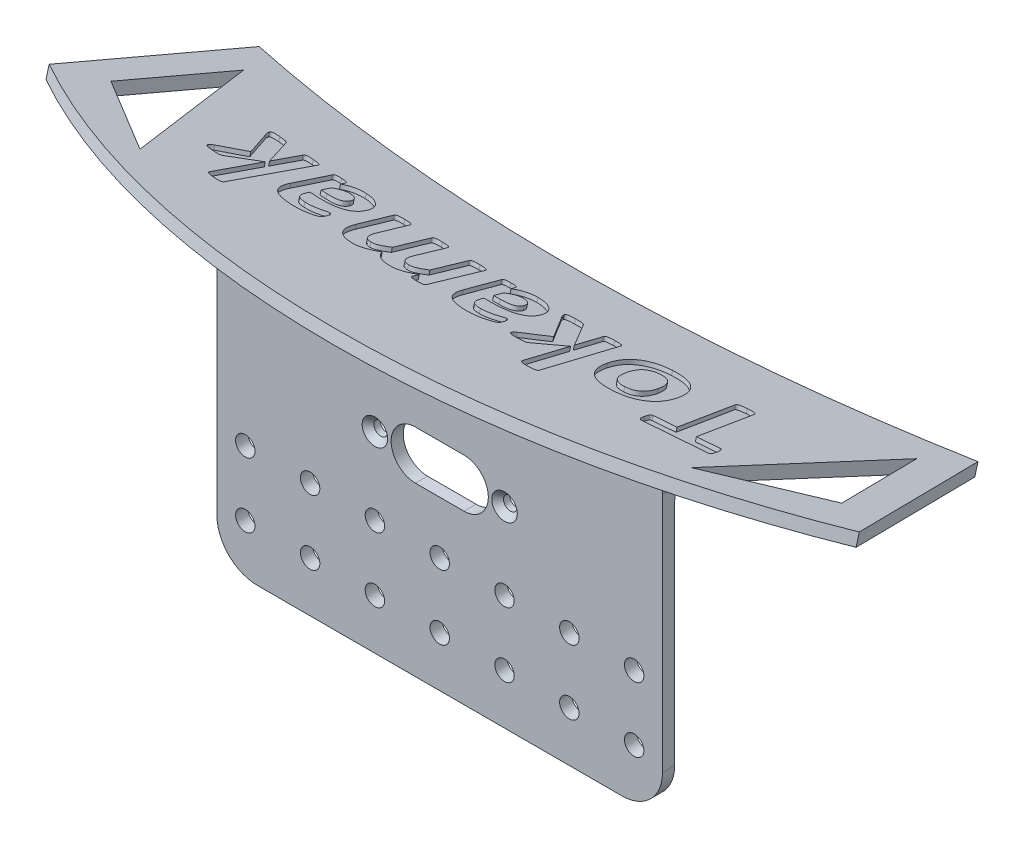
from build123d import *

# Parameters (mm, degrees)
SKETCH2_W                                           = 110
SKETCH2_H                                           = 80
BOSS_EXTRUDE1_DEPTH                                 = 3
BOSS_EXTRUDE2_DEPTH                                 = 3
FILLET1_R                                           = 10
FILLET2_R                                           = 10
SKETCH4_R                                           = 2.4
CUT_EXTRUDE1_DEPTH                                  = 45.144379945
CUT_EXTRUDE2_DEPTH                                  = 88.049621733
CUT_EXTRUDE3_DEPTH                                  = 45.144379945
CUT_EXTRUDE11_DEPTH                                 = 1
CSK_FOR_M3_COUNTERSUNK_FLAT_HEAD_SCREW1_D           = 3.4
CSK_FOR_M3_COUNTERSUNK_FLAT_HEAD_SCREW1_CSINK_D     = 6.3
CSK_FOR_M3_COUNTERSUNK_FLAT_HEAD_SCREW1_CSINK_ANGLE = 90


with BuildPart() as part:
    # Sketch2 → Boss-Extrude1 (new body)
    with BuildSketch(Plane.XY):
        Rectangle(SKETCH2_W, SKETCH2_H)
    extrude(amount=BOSS_EXTRUDE1_DEPTH)

    # Sketch3 → Boss-Extrude2 (add)
    with BuildSketch(Plane(origin=(0, 36.570508076, -9.799038106), x_dir=(-1, 0, 0), z_dir=(0, 0.965925826, -0.258819045))):
        with BuildLine():
            Line((-100, 10.352761804), (-88.746133918, -31.647238196))
            ThreePointArc((-88.746133918, -31.647238196), (0, -19.647238196), (88.746133918, -31.647238196))
            Line((88.746133918, -31.647238196), (100, 10.352761804))
            ThreePointArc((100, 10.352761804), (0, 40.352761804), (-100, 10.352761804))
        make_face()
    extrude(amount=BOSS_EXTRUDE2_DEPTH)

    # Fillet1
    fillet1_edges = [part.edges().sort_by_distance(p)[0] for p in [
        (0, 39.196152423, 0),
        (55, 39.598076211, 1.5),
        (-55, 39.598076211, 1.5),
        (0, 40, 3),
    ]]
    fillet(fillet1_edges, radius=FILLET1_R)

    # Fillet2
    fillet2_edges = [part.edges().sort_by_distance(p)[0] for p in [
        (55, -40, 1.5),
        (-55, -40, 1.5),
    ]]
    fillet(fillet2_edges, radius=FILLET2_R)

    # Sketch4 → Cut-Extrude1 (cut, through all)
    with BuildSketch(Plane.XY.offset(3)):
        with Locations((-48, -11.627322451)):
            Circle(SKETCH4_R)
        with Locations((-48, -27.627322451)):
            Circle(SKETCH4_R)
        with Locations((-32, -11.627322451)):
            Circle(SKETCH4_R)
        with Locations((-32, -27.627322451)):
            Circle(SKETCH4_R)
        with Locations((-16, -11.627322451)):
            Circle(SKETCH4_R)
        with Locations((-16, -27.627322451)):
            Circle(SKETCH4_R)
        with Locations((0, -11.627322451)):
            Circle(SKETCH4_R)
        with Locations((0, -27.627322451)):
            Circle(SKETCH4_R)
        with Locations((16, -11.627322451)):
            Circle(SKETCH4_R)
        with Locations((16, -27.627322451)):
            Circle(SKETCH4_R)
        with Locations((32, -11.627322451)):
            Circle(SKETCH4_R)
        with Locations((32, -27.627322451)):
            Circle(SKETCH4_R)
        with Locations((48, -11.627322451)):
            Circle(SKETCH4_R)
        with Locations((48, -27.627322451)):
            Circle(SKETCH4_R)
    extrude(amount=-CUT_EXTRUDE1_DEPTH, mode=Mode.SUBTRACT)

    # Sketch7 → Cut-Extrude2 (cut, through all)
    with BuildSketch(Plane(origin=(0, 39.468285555, -10.575495241), x_dir=(1, 0, 0), z_dir=(0, 0.965925826, -0.258819045))):
        Polygon((90.202041029, -4.695907555), (83.089279668, 21.849279225), (68.084935833, -20.182471336), align=None)
    cut_extrude2 = extrude(amount=-CUT_EXTRUDE2_DEPTH, mode=Mode.SUBTRACT)

    # Mirror1: Cut-Extrude2 across plane
    add(cut_extrude2.mirror(Plane(origin=(0, 0, 0), x_dir=(0, 0, 1), z_dir=(1, 0, 0))), mode=Mode.SUBTRACT)

    # Sketch8 → Cut-Extrude3 (cut, through all)
    with BuildSketch(Plane.XY.offset(3)):
        with BuildLine():
            Line((-6, 13.372677549), (6, 13.372677549))
            ThreePointArc((6, 13.372677549), (12, 7.372677549), (6, 1.372677549))
            Line((6, 1.372677549), (-6, 1.372677549))
            ThreePointArc((-6, 1.372677549), (-12, 7.372677549), (-6, 13.372677549))
        make_face()
    extrude(amount=-CUT_EXTRUDE3_DEPTH, mode=Mode.SUBTRACT)

    # Sketch9 → Cut-Extrude11 (cut)
    with BuildSketch(Plane(origin=(0, 39.468285555, -10.575495241), x_dir=(-1, 0, 0), z_dir=(0, 0.965925826, -0.258819045))):
        with BuildLine():
            add(Edge.make_bspline(
                [(-49.435540802, 12.912574756), (-49.419047282, 12.766806093), (-49.38868423, 12.498459394), (-49.373489441, 12.126485762), (-49.381697124, 11.817365886), (-49.431096559, 11.568766235), (-49.50041131, 11.372829069), (-49.599662798, 11.22991395), (-49.722304379, 11.133085391), (-49.816775888, 11.109903843), (-49.863543253, 11.098428003)],
                knots=[0, 0, 0, 0, 0.000439913, 0.000809839, 0.001116597, 0.001364597, 0.001567826, 0.001735181, 0.001881091, 0.002024135, 0.002024135, 0.002024135, 0.002024135], degree=3))
            Line((-49.863543253, 11.098428003), (-55.130891599, 10.480742648))
            Line((-55.130891599, 10.480742648), (-53.13678927, -6.483718136))
            add(Edge.make_bspline(
                [(-53.13678927, -6.483718136), (-53.13656824, -6.536066112), (-53.136115475, -6.643297684), (-53.203886208, -6.802456658), (-53.345090317, -6.938566716), (-53.550498038, -7.060477804), (-53.840402377, -7.1564185), (-54.209462235, -7.259588735), (-54.67606465, -7.350862804), (-55.02031991, -7.393958157), (-55.208710226, -7.417541666)],
                knots=[0, 0, 0, 0, 0.000155941, 0.000319435, 0.000501742, 0.000735299, 0.001030744, 0.001414234, 0.001885432, 0.002454959, 0.002454959, 0.002454959, 0.002454959], degree=3))
            add(Edge.make_bspline(
                [(-55.208710226, -7.417541666), (-55.398197325, -7.43714657), (-55.742612705, -7.47278082), (-56.215541052, -7.49746365), (-56.597035389, -7.479665504), (-56.899332696, -7.454884968), (-57.12983634, -7.388354525), (-57.296870854, -7.286539502), (-57.397257526, -7.145149407), (-57.420108111, -7.041018494), (-57.431404773, -6.989539215)],
                knots=[0, 0, 0, 0, 0.000571558, 0.001038875, 0.001418521, 0.001717152, 0.001946364, 0.002132522, 0.002293097, 0.002450096, 0.002450096, 0.002450096, 0.002450096], degree=3))
            Line((-57.431404773, -6.989539215), (-59.425507101, 9.97492157))
            Line((-59.425507101, 9.97492157), (-64.692855447, 9.357236214))
            add(Edge.make_bspline(
                [(-64.692855447, 9.357236214), (-64.745300072, 9.35466608), (-64.847646132, 9.349650444), (-64.99671576, 9.416301263), (-65.117250615, 9.540940593), (-65.227212947, 9.714749269), (-65.320843417, 9.947560411), (-65.409113535, 10.243362508), (-65.478338862, 10.61040408), (-65.514583196, 10.879378963), (-65.534269356, 11.02547304)],
                knots=[0, 0, 0, 0, 0.000155713, 0.000303875, 0.000472428, 0.000669391, 0.000917819, 0.001222488, 0.001594487, 0.00203676, 0.00203676, 0.00203676, 0.00203676], degree=3))
            add(Edge.make_bspline(
                [(-65.534269356, 11.02547304), (-65.550303573, 11.176063759), (-65.579733206, 11.452462018), (-65.600127539, 11.83475123), (-65.577555837, 12.148308605), (-65.546510771, 12.400656391), (-65.478259251, 12.593477688), (-65.384470347, 12.736103009), (-65.25309801, 12.826664268), (-65.152924702, 12.844854913), (-65.101403241, 12.854210785)],
                knots=[0, 0, 0, 0, 0.000454434, 0.00083408, 0.001145962, 0.001397042, 0.001594005, 0.00175458, 0.00190162, 0.002057334, 0.002057334, 0.002057334, 0.002057334], degree=3))
            Line((-65.101403241, 12.854210785), (-50.272091047, 14.595402574))
            add(Edge.make_bspline(
                [(-50.272091047, 14.595402574), (-50.224563522, 14.597186269), (-50.127762493, 14.600819184), (-49.986197166, 14.540170203), (-49.852320105, 14.432604305), (-49.74412026, 14.256427161), (-49.638575228, 14.022911448), (-49.564891908, 13.713807028), (-49.490342856, 13.337735663), (-49.454808113, 13.062052867), (-49.435540802, 12.912574756)],
                knots=[0, 0, 0, 0, 0.00014113, 0.000287445, 0.000449996, 0.000649643, 0.000900016, 0.001217386, 0.001598928, 0.00205083, 0.00205083, 0.00205083, 0.00205083], degree=3))
        make_face()
        with BuildLine():
            add(Edge.make_bspline(
                [(-30.946524195, 3.236077807), (-30.924372147, 2.93147708), (-30.880810355, 2.332482619), (-30.890435427, 1.447639022), (-30.968793018, 0.597295771), (-31.107678834, -0.217017933), (-31.314570488, -0.990089258), (-31.594400627, -1.719181242), (-31.944551442, -2.398361198), (-32.358870681, -3.033331995), (-32.848370828, -3.607082647), (-33.403788512, -4.130820247), (-34.033640727, -4.589766157), (-34.729241123, -4.997654468), (-35.495317559, -5.338674811), (-36.334432146, -5.603641248), (-37.240778778, -5.806214936), (-37.8730623, -5.876385605), (-38.19824754, -5.912474583)],
                knots=[0, 0, 0, 0, 0.000915933, 0.001801173, 0.002651021, 0.003475408, 0.004276512, 0.005047874, 0.005813558, 0.006564927, 0.007317208, 0.008070763, 0.008849951, 0.009649917, 0.010485972, 0.011359619, 0.012285978, 0.013266896, 0.013266896, 0.013266896, 0.013266896], degree=3))
            add(Edge.make_bspline(
                [(-38.19824754, -5.912474583), (-38.514198128, -5.935572825), (-39.124638964, -5.980200404), (-40.018078637, -5.959296442), (-40.853779683, -5.870661985), (-41.634866556, -5.705173154), (-42.357806283, -5.467506061), (-43.024015713, -5.158336265), (-43.637815283, -4.787411927), (-44.196266983, -4.347630013), (-44.695683415, -3.835880505), (-45.139367474, -3.259543384), (-45.525058449, -2.61781215), (-45.85012345, -1.912065623), (-46.121753697, -1.146498247), (-46.338225426, -0.319430344), (-46.510565021, 0.564178093), (-46.577905249, 1.176489783), (-46.612386633, 1.490022353)],
                knots=[0, 0, 0, 0, 0.000949922, 0.001835323, 0.002676962, 0.003467767, 0.004226015, 0.004954997, 0.005666507, 0.006372928, 0.007081422, 0.007806173, 0.008550203, 0.009322668, 0.010133384, 0.010983983, 0.01188539, 0.012831307, 0.012831307, 0.012831307, 0.012831307], degree=3))
            add(Edge.make_bspline(
                [(-46.612386633, 1.490022353), (-46.63461894, 1.79625077), (-46.67810783, 2.395267985), (-46.667776878, 3.281619482), (-46.591805598, 4.132564346), (-46.446274589, 4.948251359), (-46.232977424, 5.723943952), (-45.952446904, 6.452948522), (-45.603889763, 7.134332265), (-45.184065732, 7.76075836), (-44.701603498, 8.341819136), (-44.142412837, 8.856755765), (-43.520366675, 9.318121364), (-42.828115899, 9.717645013), (-42.067549368, 10.061414399), (-41.230647478, 10.323816682), (-40.326415551, 10.52812925), (-39.695620262, 10.597793249), (-39.370390616, 10.633711079)],
                knots=[0, 0, 0, 0, 0.000920788, 0.001801165, 0.002655856, 0.00348109, 0.004283477, 0.005065665, 0.005820474, 0.00657453, 0.007323676, 0.008080785, 0.008849259, 0.009642574, 0.010474189, 0.011347836, 0.012269446, 0.013250364, 0.013250364, 0.013250364, 0.013250364], degree=3))
            add(Edge.make_bspline(
                [(-39.370390616, 10.633711079), (-39.052834195, 10.656100507), (-38.435974979, 10.699592386), (-37.537462627, 10.687863063), (-36.697175158, 10.59554366), (-35.916414529, 10.431423442), (-35.191034379, 10.196636996), (-34.51946894, 9.898457683), (-33.91300641, 9.516914929), (-33.357199055, 9.079068427), (-32.864611749, 8.567000296), (-32.423295413, 7.993460846), (-32.038346935, 7.353753829), (-31.714922148, 6.646859313), (-31.435632247, 5.883451654), (-31.221219591, 5.055079597), (-31.04736745, 4.16856184), (-30.980785964, 3.552891781), (-30.946524195, 3.236077807)],
                knots=[0, 0, 0, 0, 0.000954778, 0.001854674, 0.002691479, 0.003487041, 0.004243775, 0.004975154, 0.005685066, 0.006387676, 0.007092773, 0.007810704, 0.008554733, 0.009327199, 0.010139562, 0.010990161, 0.011891567, 0.012847138, 0.012847138, 0.012847138, 0.012847138], degree=3))
        make_face()
        with BuildLine():
            add(Edge.make_bspline(
                [(-35.187639391, 2.681620086), (-35.225868163, 3.028035026), (-35.299361859, 3.694007612), (-35.486966653, 4.496028388), (-35.675942432, 5.083474605), (-35.838997474, 5.48687693), (-36.040931102, 5.850931955), (-36.264012907, 6.185710248), (-36.517638403, 6.481982339), (-36.797515337, 6.747065279), (-37.114164507, 6.963060832), (-37.460736219, 7.143372938), (-37.842520154, 7.273724898), (-38.264087325, 7.357864053), (-38.725202554, 7.384417121), (-39.044609138, 7.365427693), (-39.209889697, 7.355601397)],
                knots=[0, 0, 0, 0, 0.001044873, 0.002008738, 0.002464004, 0.002895748, 0.003311471, 0.003710765, 0.004100618, 0.004479172, 0.004863679, 0.00524652, 0.005647971, 0.00606957, 0.006532539, 0.007029014, 0.007029014, 0.007029014, 0.007029014], degree=3))
            add(Edge.make_bspline(
                [(-39.209889697, 7.355601397), (-39.357977543, 7.337763492), (-39.645552737, 7.303123652), (-40.057954443, 7.198626895), (-40.439037656, 7.058995835), (-40.78773398, 6.878230963), (-41.100624223, 6.657638683), (-41.381632312, 6.401095229), (-41.630349586, 6.109870963), (-41.840434669, 5.779717095), (-42.014094404, 5.417504466), (-42.160796929, 5.025328507), (-42.277684171, 4.602370187), (-42.357232586, 4.14942975), (-42.413408421, 3.668725745), (-42.427329554, 3.160020632), (-42.426934606, 2.620889319), (-42.396633733, 2.253502762), (-42.380998766, 2.063934731)],
                knots=[0, 0, 0, 0, 0.000447087, 0.000868208, 0.001272946, 0.001662343, 0.00204286, 0.00241812, 0.002801116, 0.00318832, 0.003588561, 0.004004113, 0.004443057, 0.004902873, 0.005382505, 0.00589356, 0.006428585, 0.006998963, 0.006998963, 0.006998963, 0.006998963], degree=3))
            add(Edge.make_bspline(
                [(-42.380998766, 2.063934731), (-42.340786172, 1.717554477), (-42.263094561, 1.048340246), (-42.074427637, 0.242344995), (-41.880072254, -0.347174059), (-41.705844991, -0.745749094), (-41.515486369, -1.114554781), (-41.293992726, -1.448815786), (-41.047845467, -1.749500564), (-40.761466394, -2.003068994), (-40.446940602, -2.220000392), (-40.099947259, -2.397300652), (-39.714585269, -2.524264951), (-39.292525902, -2.600267158), (-38.833807505, -2.629737687), (-38.51757722, -2.610353316), (-38.353884795, -2.600319252)],
                knots=[0, 0, 0, 0, 0.001045518, 0.002019964, 0.00247676, 0.002905922, 0.003323631, 0.003720221, 0.004106936, 0.004485802, 0.004863543, 0.005250717, 0.005650603, 0.006076056, 0.006534171, 0.007025786, 0.007025786, 0.007025786, 0.007025786], degree=3))
            add(Edge.make_bspline(
                [(-38.353884795, -2.600319252), (-38.204235486, -2.582273939), (-37.912002841, -2.547035355), (-37.494032105, -2.445063786), (-37.110190982, -2.303550189), (-36.761418165, -2.123008341), (-36.448639028, -1.902277574), (-36.168958206, -1.647611907), (-35.923668492, -1.358261409), (-35.714458584, -1.033162574), (-35.533058779, -0.677014219), (-35.388749639, -0.286496873), (-35.276002762, 0.13516017), (-35.201012806, 0.588158725), (-35.152482657, 1.07067215), (-35.134311999, 1.582291521), (-35.143491684, 2.12301416), (-35.172657111, 2.492047611), (-35.187639391, 2.681620086)],
                knots=[0, 0, 0, 0, 0.000451902, 0.000882467, 0.001287205, 0.001676602, 0.002057119, 0.002432378, 0.002808519, 0.003191639, 0.003589688, 0.004005239, 0.004438215, 0.004897181, 0.005381134, 0.005892189, 0.006432143, 0.007002521, 0.007002521, 0.007002521, 0.007002521], degree=3))
        make_face(mode=Mode.SUBTRACT)
        with BuildLine():
            add(Edge.make_bspline(
                [(-13.429206078, -3.861509075), (-13.430608169, -3.9123684), (-13.433400011, -4.013639405), (-13.502451139, -4.161455632), (-13.641681445, -4.283003107), (-13.852326652, -4.371276087), (-14.136676775, -4.439623246), (-14.508309263, -4.504710206), (-14.986578595, -4.543551811), (-15.34219856, -4.55845145), (-15.540036348, -4.566740387)],
                knots=[0, 0, 0, 0, 0.000151478, 0.000301623, 0.000473717, 0.000693498, 0.000980166, 0.00135038, 0.001824182, 0.002418266, 0.002418266, 0.002418266, 0.002418266], degree=3))
            add(Edge.make_bspline(
                [(-15.540036348, -4.566740387), (-15.742638602, -4.570376581), (-16.107310021, -4.576921504), (-16.599557695, -4.580585338), (-16.992587428, -4.543432733), (-17.307209589, -4.495941231), (-17.558553022, -4.41657264), (-17.751926483, -4.297205758), (-17.905321083, -4.141874612), (-17.983893309, -4.018855868), (-18.025368762, -3.953918696)],
                knots=[0, 0, 0, 0, 0.000608036, 0.001094427, 0.001475317, 0.001791156, 0.002048011, 0.002259901, 0.002466249, 0.002696953, 0.002696953, 0.002696953, 0.002696953], degree=3))
            Line((-18.025368762, -3.953918696), (-23.141943517, 3.604215496))
            Line((-23.141943517, 3.604215496), (-22.898760306, -4.1436016))
            add(Edge.make_bspline(
                [(-22.898760306, -4.1436016), (-22.901155918, -4.196495252), (-22.905911169, -4.301488273), (-22.988350405, -4.445894559), (-23.126657442, -4.571579088), (-23.338588538, -4.661289561), (-23.618124811, -4.738025225), (-23.976542337, -4.799426003), (-24.426795714, -4.840523742), (-24.758206837, -4.855268867), (-24.941499277, -4.863423904)],
                knots=[0, 0, 0, 0, 0.000156848, 0.000311342, 0.000483436, 0.000709687, 0.000992952, 0.001353585, 0.001798338, 0.002348706, 0.002348706, 0.002348706, 0.002348706], degree=3))
            add(Edge.make_bspline(
                [(-24.941499277, -4.863423904), (-25.126303834, -4.866404361), (-25.46194262, -4.871817414), (-25.916821912, -4.860929412), (-26.281697029, -4.82404495), (-26.565175228, -4.76434372), (-26.78037662, -4.683362287), (-26.933591154, -4.576284614), (-27.020000507, -4.431697514), (-27.031754004, -4.327814721), (-27.037738553, -4.274920534)],
                knots=[0, 0, 0, 0, 0.000554479, 0.001007035, 0.001364208, 0.0016533, 0.001873673, 0.002050713, 0.002203357, 0.002361707, 0.002361707, 0.002361707, 0.002361707], degree=3))
            Line((-27.037738553, -4.274920534), (-27.718651544, 17.310021255))
            add(Edge.make_bspline(
                [(-27.718651544, 17.310021255), (-27.71584568, 17.364280194), (-27.710321657, 17.471102059), (-27.634352774, 17.625232917), (-27.492777483, 17.754305734), (-27.283126724, 17.860393631), (-27.00145922, 17.944025752), (-26.639280956, 18.008873514), (-26.186425551, 18.064024439), (-25.85121601, 18.07647264), (-25.666185245, 18.083343866)],
                knots=[0, 0, 0, 0, 0.000161676, 0.000318298, 0.000500604, 0.000726908, 0.001017632, 0.00137915, 0.001829794, 0.002385019, 0.002385019, 0.002385019, 0.002385019], degree=3))
            add(Edge.make_bspline(
                [(-25.666185245, 18.083343866), (-25.482905758, 18.087792977), (-25.150193216, 18.095869578), (-24.69928129, 18.068860754), (-24.335488247, 18.033190414), (-24.054724914, 17.957410477), (-23.833763161, 17.874023209), (-23.691475922, 17.74407636), (-23.596786405, 17.601297391), (-23.585366065, 17.494550824), (-23.579673296, 17.441340189)],
                knots=[0, 0, 0, 0, 0.000549616, 0.000997733, 0.001355469, 0.001642136, 0.00187078, 0.002053346, 0.002212663, 0.002371013, 0.002371013, 0.002371013, 0.002371013], degree=3))
            Line((-23.579673296, 17.441340189), (-23.171125502, 4.586675667))
            Line((-23.171125502, 4.586675667), (-19.022419926, 10.549527996))
            add(Edge.make_bspline(
                [(-19.022419926, 10.549527996), (-18.978072875, 10.613490915), (-18.891842528, 10.737863214), (-18.742659364, 10.914302565), (-18.549183636, 11.059122295), (-18.295450629, 11.15956003), (-17.989768562, 11.238962898), (-17.612365054, 11.303112144), (-17.14898929, 11.343454101), (-16.807905706, 11.358386904), (-16.619769803, 11.366623584)],
                knots=[0, 0, 0, 0, 0.000233507, 0.00045404, 0.000690416, 0.0009497, 0.001267071, 0.001637285, 0.00209656, 0.002661499, 0.002661499, 0.002661499, 0.002661499], degree=3))
            add(Edge.make_bspline(
                [(-16.619769803, 11.366623584), (-16.433266948, 11.372797689), (-16.090963224, 11.384129523), (-15.620925059, 11.358960964), (-15.235016685, 11.335595183), (-14.934612843, 11.26958048), (-14.704856028, 11.197736236), (-14.554098012, 11.076972633), (-14.467280974, 10.928542161), (-14.456269164, 10.819769545), (-14.450575563, 10.763529221)],
                knots=[0, 0, 0, 0, 0.000559406, 0.001026723, 0.001412458, 0.001715804, 0.001949766, 0.002126002, 0.002282851, 0.00245077, 0.00245077, 0.00245077, 0.00245077], degree=3))
            add(Edge.make_bspline(
                [(-14.450575563, 10.763529221), (-14.453026313, 10.67696748), (-14.458175547, 10.495093856), (-14.551234949, 10.219555093), (-14.695911408, 9.924774101), (-14.830105017, 9.733856085), (-14.902896335, 9.630295459)],
                knots=[0, 0, 0, 0, 0.000258507, 0.000543146, 0.000862893, 0.001241946, 0.001241946, 0.001241946, 0.001241946], degree=3))
            Line((-14.902896335, 9.630295459), (-19.037010919, 4.635312309))
            Line((-19.037010919, 4.635312309), (-13.832890208, -2.87418524))
            add(Edge.make_bspline(
                [(-13.832890208, -2.87418524), (-13.770484565, -2.971754938), (-13.656820514, -3.149465906), (-13.533892662, -3.411440227), (-13.45126851, -3.642668502), (-13.436290062, -3.791241972), (-13.429206078, -3.861509075)],
                knots=[0, 0, 0, 0, 0.000346994, 0.000632007, 0.00086733, 0.001078493, 0.001078493, 0.001078493, 0.001078493], degree=3))
        make_face()
        with BuildLine():
            add(Edge.make_bspline(
                [(1.713976908, -3.568886058), (1.708537355, -3.641279668), (1.697970011, -3.781917708), (1.547672494, -3.954891047), (1.316152867, -4.057359908), (1.07335676, -4.117251506), (0.824306665, -4.145146593), (0.585995988, -4.165694698), (0.30354614, -4.172919052), (0.10085688, -4.175474612), (-0.007760224, -4.176844085)],
                knots=[0, 0, 0, 0, 0.000212726, 0.00041326, 0.000648181, 0.000964319, 0.00116038, 0.001399492, 0.001681752, 0.002007654, 0.002007654, 0.002007654, 0.002007654], degree=3))
            add(Edge.make_bspline(
                [(-0.007760224, -4.176844085), (-0.122877701, -4.175733899), (-0.335321929, -4.1736851), (-0.628820628, -4.163636001), (-0.872431717, -4.151468934), (-1.116817868, -4.122746565), (-1.347850166, -4.064261864), (-1.562375187, -3.955433936), (-1.680977647, -3.774297649), (-1.690423475, -3.640245243), (-1.695451707, -3.568886058)],
                knots=[0, 0, 0, 0, 0.000345354, 0.000637336, 0.000880957, 0.001077017, 0.001374338, 0.00159455, 0.001780708, 0.001992599, 0.001992599, 0.001992599, 0.001992599], degree=3))
            Line((-1.695451707, -3.568886058), (-1.695451707, -2.40647031))
            add(Edge.make_bspline(
                [(-1.695451707, -2.40647031), (-1.848265666, -2.561891294), (-2.152246692, -2.871058273), (-2.655401546, -3.278421555), (-3.18959748, -3.636119907), (-3.75235406, -3.94373096), (-4.34915616, -4.191928008), (-4.982832591, -4.357796897), (-5.645558597, -4.471128907), (-6.099819593, -4.482396273), (-6.330523704, -4.488118594)],
                knots=[0, 0, 0, 0, 0.000653471, 0.001299899, 0.001937948, 0.00257997, 0.003221237, 0.003871332, 0.004541389, 0.005232868, 0.005232868, 0.005232868, 0.005232868], degree=3))
            add(Edge.make_bspline(
                [(-6.330523704, -4.488118594), (-6.522009263, -4.484734019), (-6.896179121, -4.478120434), (-7.445130139, -4.41597004), (-7.970934654, -4.326410871), (-8.472472486, -4.195519053), (-8.944349065, -4.025632143), (-9.385097802, -3.819761879), (-9.796215966, -3.582388503), (-10.172795675, -3.304821964), (-10.509160312, -2.98665821), (-10.808119346, -2.634548103), (-11.066267272, -2.24732915), (-11.289245621, -1.827436821), (-11.457159305, -1.365121958), (-11.58512785, -0.868911955), (-11.65763775, -0.333437478), (-11.666340177, 0.034875557), (-11.670827013, 0.224772031)],
                knots=[0, 0, 0, 0, 0.000574242, 0.00112209, 0.001655433, 0.002173316, 0.002674863, 0.003157911, 0.003630888, 0.004096836, 0.004557885, 0.005016851, 0.005479539, 0.005951615, 0.006439462, 0.006951419, 0.007486555, 0.008056123, 0.008056123, 0.008056123, 0.008056123], degree=3))
            add(Edge.make_bspline(
                [(-11.670827013, 0.224772031), (-11.666604575, 0.429528539), (-11.658408933, 0.826955632), (-11.555326331, 1.400794604), (-11.403485528, 1.935208113), (-11.181382956, 2.427743185), (-10.897842813, 2.877589199), (-10.552443282, 3.286734298), (-10.14421517, 3.653465552), (-9.673043706, 3.980416434), (-9.139907354, 4.265690627), (-8.549314779, 4.514604459), (-7.897084186, 4.716976038), (-7.184948385, 4.881743294), (-6.412597174, 5.004194435), (-5.581840671, 5.097920932), (-4.692124578, 5.149549533), (-4.078709327, 5.15736337), (-3.762508999, 5.16139121)],
                knots=[0, 0, 0, 0, 0.000613516, 0.001190819, 0.001743332, 0.002276674, 0.00280563, 0.003333713, 0.003877792, 0.004447173, 0.005049992, 0.005688634, 0.006366989, 0.007096085, 0.007879678, 0.008711649, 0.009603306, 0.01055192, 0.01055192, 0.01055192, 0.01055192], degree=3))
            Line((-3.762508999, 5.16139121), (-2.332591719, 5.16139121))
            Line((-2.332591719, 5.16139121), (-2.332591719, 6.075760082))
            add(Edge.make_bspline(
                [(-2.332591719, 6.075760082), (-2.337510378, 6.298487892), (-2.346732934, 6.716105707), (-2.455988776, 7.299086883), (-2.625322311, 7.804649572), (-2.911280088, 8.21448015), (-3.288647256, 8.542842604), (-3.690181172, 8.711406759), (-4.053103919, 8.805891623), (-4.364145386, 8.857323107), (-4.706842704, 8.893259365), (-4.945893938, 8.895509361), (-5.070834673, 8.896685327)],
                knots=[0, 0, 0, 0, 0.000667191, 0.001250993, 0.001774148, 0.002253089, 0.002732623, 0.003255099, 0.003541766, 0.003857605, 0.00419976, 0.004574388, 0.004574388, 0.004574388, 0.004574388], degree=3))
            add(Edge.make_bspline(
                [(-5.070834673, 8.896685327), (-5.236292066, 8.893967282), (-5.558089297, 8.888680971), (-6.0281565, 8.845250097), (-6.470590836, 8.768397148), (-7.009368774, 8.624901857), (-7.625175548, 8.418729269), (-8.283539028, 8.136767637), (-8.847610632, 7.861561697), (-9.248236004, 7.636555248), (-9.51985941, 7.474826892), (-9.700750908, 7.407183576), (-9.858010981, 7.348866648), (-9.960010707, 7.343028347), (-10.007453852, 7.340312778)],
                knots=[0, 0, 0, 0, 0.000496308, 0.000965267, 0.00141465, 0.001841684, 0.002636845, 0.00336042, 0.003989038, 0.004518128, 0.004740158, 0.00493434, 0.0050974, 0.005239199, 0.005239199, 0.005239199, 0.005239199], degree=3))
            add(Edge.make_bspline(
                [(-10.007453852, 7.340312778), (-10.065165326, 7.34623064), (-10.178133322, 7.357814629), (-10.33594318, 7.443627212), (-10.459732065, 7.585506057), (-10.565030264, 7.772231992), (-10.636144299, 8.006695354), (-10.696258966, 8.281252269), (-10.72683732, 8.596122693), (-10.733506605, 8.818825683), (-10.737003484, 8.935594641)],
                knots=[0, 0, 0, 0, 0.000172711, 0.000338076, 0.000523916, 0.000730837, 0.000976921, 0.001255469, 0.001573435, 0.001923923, 0.001923923, 0.001923923, 0.001923923], degree=3))
            add(Edge.make_bspline(
                [(-10.737003484, 8.935594641), (-10.733699544, 9.081510807), (-10.727827097, 9.340863232), (-10.678011672, 9.699464703), (-10.546209539, 9.990612572), (-10.382434679, 10.199734541), (-10.203340187, 10.357118578), (-10.02252133, 10.486139405), (-9.800982521, 10.627617436), (-9.439764852, 10.841695586), (-8.914481527, 11.112323922), (-8.198718188, 11.391459267), (-7.407675461, 11.653038224), (-6.543198021, 11.847297716), (-5.631254204, 11.985628824), (-5.006509533, 12.001451505), (-4.691468864, 12.009430425)],
                knots=[0, 0, 0, 0, 0.000438162, 0.000778792, 0.001077066, 0.001385477, 0.001568043, 0.001790818, 0.002051195, 0.002356484, 0.00305037, 0.003820766, 0.004659026, 0.005547427, 0.006475992, 0.007420557, 0.007420557, 0.007420557, 0.007420557], degree=3))
            add(Edge.make_bspline(
                [(-4.691468864, 12.009430425), (-4.417367772, 12.006252301), (-3.887828485, 12.000112444), (-3.12554732, 11.937824358), (-2.425490249, 11.830260231), (-1.784896475, 11.687657588), (-1.201994631, 11.496899712), (-0.671956643, 11.266646668), (-0.201026459, 10.979475299), (0.222464392, 10.653913177), (0.590552873, 10.275373194), (0.904263669, 9.848026609), (1.164577919, 9.370565859), (1.367330777, 8.841272668), (1.519123929, 8.263050616), (1.640045951, 7.638164436), (1.697766545, 6.960403666), (1.708456476, 6.492489527), (1.713976908, 6.250851994)],
                knots=[0, 0, 0, 0, 0.000822189, 0.001588398, 0.002292085, 0.002945718, 0.003554784, 0.004129603, 0.004675114, 0.005205343, 0.005728136, 0.006253434, 0.00679104, 0.007354637, 0.007949279, 0.008582676, 0.009261676, 0.00998677, 0.00998677, 0.00998677, 0.00998677], degree=3))
            Line((1.713976908, 6.250851994), (1.713976908, -3.568886058))
        make_face()
        with BuildLine():
            Line((-2.332591719, 2.671195131), (-3.908418925, 2.671195131))
            add(Edge.make_bspline(
                [(-3.908418925, 2.671195131), (-4.068969295, 2.669463509), (-4.379004444, 2.666119613), (-4.825400122, 2.636917267), (-5.236471945, 2.589614098), (-5.609498385, 2.520726456), (-5.951143923, 2.441041446), (-6.255288373, 2.331917393), (-6.53272457, 2.213814779), (-6.840960584, 2.021504066), (-7.168300789, 1.747333029), (-7.439760739, 1.331926444), (-7.59533494, 0.854815482), (-7.614325074, 0.517790276), (-7.624258386, 0.341499972)],
                knots=[0, 0, 0, 0, 0.000481601, 0.000930009, 0.001341441, 0.001722083, 0.002067712, 0.002392268, 0.002690542, 0.00296998, 0.003480132, 0.003957664, 0.004439068, 0.004967061, 0.004967061, 0.004967061, 0.004967061], degree=3))
            add(Edge.make_bspline(
                [(-7.624258386, 0.341499972), (-7.616491079, 0.19177272), (-7.601582851, -0.095607204), (-7.496282128, -0.504313692), (-7.304943006, -0.857249339), (-7.048766463, -1.160036725), (-6.724553427, -1.400668695), (-6.337699157, -1.565708111), (-5.898286415, -1.670277001), (-5.585411155, -1.681009092), (-5.421018496, -1.686648006)],
                knots=[0, 0, 0, 0, 0.000449146, 0.00086207, 0.001253739, 0.001643591, 0.002043389, 0.002452776, 0.002897528, 0.003389937, 0.003389937, 0.003389937, 0.003389937], degree=3))
            add(Edge.make_bspline(
                [(-5.421018496, -1.686648006), (-5.27784544, -1.681342493), (-4.995228432, -1.670869654), (-4.583285153, -1.578327626), (-4.187690806, -1.437560898), (-3.810343797, -1.231413499), (-3.43631745, -0.976501899), (-3.071618185, -0.659997567), (-2.690605439, -0.306825285), (-2.454984227, -0.036986346), (-2.332591719, 0.103180425)],
                knots=[0, 0, 0, 0, 0.000428996, 0.000846819, 0.001260688, 0.001684971, 0.002132851, 0.002616094, 0.003132147, 0.003689965, 0.003689965, 0.003689965, 0.003689965], degree=3))
            Line((-2.332591719, 0.103180425), (-2.332591719, 2.671195131))
        make_face(mode=Mode.SUBTRACT)
        with BuildLine():
            add(Edge.make_bspline(
                [(28.958567692, -4.256767052), (28.95261861, -4.309706692), (28.940934769, -4.413678751), (28.854676548, -4.556445392), (28.706888361, -4.665690699), (28.497155425, -4.745385017), (28.217510423, -4.807625862), (27.855344722, -4.841895798), (27.402272836, -4.853946446), (27.069846268, -4.848352972), (26.886646736, -4.845270422)],
                knots=[0, 0, 0, 0, 0.000158349, 0.000310994, 0.000484184, 0.000700056, 0.000979664, 0.001341673, 0.001789367, 0.002338983, 0.002338983, 0.002338983, 0.002338983], degree=3))
            add(Edge.make_bspline(
                [(26.886646736, -4.845270422), (26.696926553, -4.83698639), (26.355897469, -4.822095535), (25.896872299, -4.783180022), (25.536747798, -4.717375136), (25.256993775, -4.647293212), (25.052404862, -4.549647391), (24.910512831, -4.43181879), (24.849964347, -4.279264149), (24.842752642, -4.177684403), (24.839044101, -4.125448118)],
                knots=[0, 0, 0, 0, 0.000569796, 0.00102423, 0.001380076, 0.00166802, 0.00188553, 0.002057624, 0.002205786, 0.002362635, 0.002362635, 0.002362635, 0.002362635], degree=3))
            Line((24.839044101, -4.125448118), (25.111409297, 4.556192507))
            add(Edge.make_bspline(
                [(25.111409297, 4.556192507), (25.114549261, 4.793247002), (25.120554101, 5.246587944), (25.028722779, 5.891250551), (24.88264552, 6.468845828), (24.640795674, 6.96204275), (24.329607551, 7.375041759), (23.993481082, 7.627487877), (23.69514663, 7.778575029), (23.444175703, 7.860336491), (23.171352926, 7.914309358), (22.981379316, 7.92571835), (22.883851087, 7.931575473)],
                knots=[0, 0, 0, 0, 0.000710162, 0.001358107, 0.001948055, 0.002489672, 0.002995587, 0.003484887, 0.003735023, 0.003996487, 0.004274057, 0.004566889, 0.004566889, 0.004566889, 0.004566889], degree=3))
            add(Edge.make_bspline(
                [(22.883851087, 7.931575473), (22.760006206, 7.928333321), (22.505228623, 7.921663464), (22.124478535, 7.816079831), (21.737479844, 7.649393047), (21.355265981, 7.397878823), (20.957819586, 7.087795353), (20.546695477, 6.710520123), (20.113122044, 6.272426167), (19.827876235, 5.950302433), (19.678696368, 5.781835889)],
                knots=[0, 0, 0, 0, 0.000370438, 0.000762076, 0.001175916, 0.001630636, 0.002129725, 0.002687543, 0.003303157, 0.003978103, 0.003978103, 0.003978103, 0.003978103], degree=3))
            Line((19.678696368, 5.781835889), (19.372285523, -3.950356206))
            add(Edge.make_bspline(
                [(19.372285523, -3.950356206), (19.366333156, -4.003288104), (19.354642864, -4.107244958), (19.268433775, -4.250127408), (19.117453345, -4.361013353), (18.903317832, -4.443976833), (18.618054887, -4.505293893), (18.256144877, -4.540402593), (17.807867945, -4.552354194), (17.480315505, -4.546783611), (17.300364567, -4.543723241)],
                knots=[0, 0, 0, 0, 0.000158349, 0.000310994, 0.000484184, 0.000710906, 0.000995254, 0.001357262, 0.001800096, 0.002339985, 0.002339985, 0.002339985, 0.002339985], degree=3))
            add(Edge.make_bspline(
                [(17.300364567, -4.543723241), (17.115495174, -4.535412119), (16.780927948, -4.520371072), (16.328544455, -4.481160481), (15.969702041, -4.416145616), (15.689333859, -4.34456996), (15.480390273, -4.248331199), (15.336381724, -4.129398061), (15.261247891, -3.980202629), (15.25561846, -3.876514919), (15.252761932, -3.823900937)],
                knots=[0, 0, 0, 0, 0.000555225, 0.001004818, 0.001360664, 0.001648608, 0.001870479, 0.002046177, 0.002198434, 0.002355283, 0.002355283, 0.002355283, 0.002355283], degree=3))
            Line((15.252761932, -3.823900937), (15.525127128, 4.857739688))
            add(Edge.make_bspline(
                [(15.525127128, 4.857739688), (15.528170732, 5.094745737), (15.533991294, 5.54799403), (15.443412133, 6.193286181), (15.293540901, 6.767434041), (15.066311086, 7.266342773), (14.750335129, 7.677032173), (14.413845795, 7.935644818), (14.111030511, 8.082307381), (13.863623283, 8.168633416), (13.594156789, 8.214082512), (13.407943565, 8.226655439), (13.31215991, 8.233122654)],
                knots=[0, 0, 0, 0, 0.000710162, 0.001358107, 0.001948055, 0.002485463, 0.002991377, 0.003487495, 0.003741991, 0.003998846, 0.004270733, 0.004558717, 0.004558717, 0.004558717, 0.004558717], degree=3))
            add(Edge.make_bspline(
                [(13.31215991, 8.233122654), (13.185021671, 8.230177475), (12.926901127, 8.224198068), (12.541902811, 8.116571035), (12.152140162, 7.952437309), (11.769209241, 7.699072221), (11.371841881, 7.390823383), (10.965675748, 7.011502653), (10.536664074, 6.575228565), (10.257554556, 6.252064007), (10.111868856, 6.083383071)],
                knots=[0, 0, 0, 0, 0.000380144, 0.000771783, 0.001190086, 0.001644806, 0.002143895, 0.002698118, 0.003310322, 0.003978788, 0.003978788, 0.003978788, 0.003978788], degree=3))
            Line((10.111868856, 6.083383071), (9.805458011, -3.648809025))
            add(Edge.make_bspline(
                [(9.805458011, -3.648809025), (9.799881368, -3.701977931), (9.78883968, -3.807251751), (9.695916599, -3.947128335), (9.546331955, -4.059819763), (9.331410639, -4.142296431), (9.046445734, -4.20379289), (8.68280848, -4.239018772), (8.229698825, -4.250777262), (7.897278493, -4.245232026), (7.714082398, -4.242176059)],
                knots=[0, 0, 0, 0, 0.000158349, 0.00031353, 0.00048672, 0.000713442, 0.00099779, 0.001359798, 0.001807493, 0.002357108, 0.002357108, 0.002357108, 0.002357108], degree=3))
            add(Edge.make_bspline(
                [(7.714082398, -4.242176059), (7.529214488, -4.233864285), (7.194649946, -4.218822059), (6.742250354, -4.179618545), (6.383451823, -4.114584388), (6.10296577, -4.043060552), (5.89432893, -3.946686935), (5.748344167, -3.827175694), (5.675868938, -3.674881415), (5.669610994, -3.569979119), (5.666479763, -3.517490091)],
                knots=[0, 0, 0, 0, 0.000555225, 0.001004818, 0.001360664, 0.001648608, 0.001870479, 0.002046177, 0.002202799, 0.002359648, 0.002359648, 0.002359648, 0.002359648], degree=3))
            Line((5.666479763, -3.517490091), (6.128527863, 11.122139198))
            add(Edge.make_bspline(
                [(6.128527863, 11.122139198), (6.133536254, 11.174666071), (6.143178564, 11.275792463), (6.211284704, 11.42088457), (6.342061164, 11.535617455), (6.534420246, 11.615370942), (6.781983619, 11.675941028), (7.097070457, 11.711452287), (7.483650186, 11.730917741), (7.767560869, 11.724105067), (7.923219959, 11.720369897)],
                knots=[0, 0, 0, 0, 0.000157526, 0.000303273, 0.000468495, 0.000666536, 0.000922515, 0.001231386, 0.001616108, 0.002083045, 0.002083045, 0.002083045, 0.002083045], degree=3))
            add(Edge.make_bspline(
                [(7.923219959, 11.720369897), (8.083877451, 11.714406846), (8.373401387, 11.703660717), (8.765108162, 11.660646586), (9.072740785, 11.601677377), (9.304512129, 11.523032009), (9.479080951, 11.434044791), (9.585610691, 11.306939024), (9.656826987, 11.166475706), (9.658628949, 11.063036587), (9.659548084, 11.010274921)],
                knots=[0, 0, 0, 0, 0.000482116, 0.000868831, 0.001181698, 0.001418574, 0.001603776, 0.001758881, 0.001909025, 0.002065345, 0.002065345, 0.002065345, 0.002065345], degree=3))
            Line((9.659548084, 11.010274921), (9.606047778, 9.322583438))
            add(Edge.make_bspline(
                [(9.606047778, 9.322583438), (9.812002743, 9.525484733), (10.209255632, 9.916847597), (10.837246266, 10.428206123), (11.45392526, 10.865049118), (12.071972585, 11.222277039), (12.697159433, 11.492343851), (13.332446998, 11.678011024), (13.977468105, 11.792984141), (14.41250198, 11.79321122), (14.630212913, 11.79332486)],
                knots=[0, 0, 0, 0, 0.000866906, 0.001672118, 0.002426378, 0.003132196, 0.003809784, 0.004463851, 0.005114711, 0.005766732, 0.005766732, 0.005766732, 0.005766732], degree=3))
            add(Edge.make_bspline(
                [(14.630212913, 11.79332486), (14.916625265, 11.777527962), (15.462274272, 11.747433026), (16.231657415, 11.570361699), (16.915882163, 11.320173508), (17.517164347, 10.983594291), (18.043958293, 10.581693758), (18.478775908, 10.099654944), (18.846466513, 9.56514325), (19.027655471, 9.171609837), (19.119374984, 8.972399615)],
                knots=[0, 0, 0, 0, 0.000859108, 0.001636701, 0.002358509, 0.003037822, 0.003696449, 0.004336719, 0.004977487, 0.00563437, 0.00563437, 0.00563437, 0.00563437], degree=3))
            add(Edge.make_bspline(
                [(19.119374984, 8.972399615), (19.339722201, 9.188494445), (19.761731247, 9.602359317), (20.424023054, 10.14028832), (21.068185105, 10.585947826), (21.705299685, 10.937904759), (22.333584381, 11.205100258), (22.964861488, 11.38074375), (23.596898792, 11.484002379), (24.019949865, 11.485944661), (24.231086074, 11.486914014)],
                knots=[0, 0, 0, 0, 0.000925439, 0.001772401, 0.002556191, 0.003272356, 0.003952522, 0.004599225, 0.005234133, 0.005866709, 0.005866709, 0.005866709, 0.005866709], degree=3))
            add(Edge.make_bspline(
                [(24.231086074, 11.486914014), (24.465043212, 11.473865137), (24.916059897, 11.448709839), (25.561476839, 11.334967623), (26.150431145, 11.169803046), (26.675384216, 10.931290113), (27.145910142, 10.647158159), (27.568066459, 10.321401063), (27.935882737, 9.945748776), (28.257037739, 9.532525963), (28.529790937, 9.080765084), (28.76162336, 8.596522904), (28.939349127, 8.073233006), (29.07367009, 7.519223035), (29.168940601, 6.941735975), (29.232155651, 6.345784003), (29.262390338, 5.735091959), (29.254407961, 5.323045726), (29.250387545, 5.115513892)],
                knots=[0, 0, 0, 0, 0.000702408, 0.001354085, 0.001962043, 0.00253242, 0.003077932, 0.00360816, 0.00412748, 0.004650884, 0.005174716, 0.005707726, 0.006258374, 0.006829311, 0.007416204, 0.00801293, 0.008626446, 0.009249014, 0.009249014, 0.009249014, 0.009249014], degree=3))
            Line((29.250387545, 5.115513892), (28.958567692, -4.256767052))
        make_face()
        with BuildLine():
            add(Edge.make_bspline(
                [(45.535483429, -5.726412349), (45.522873758, -5.797553503), (45.498417707, -5.935529476), (45.338080561, -6.098799939), (45.096824539, -6.184006781), (44.846645757, -6.226774108), (44.593516917, -6.226966286), (44.353443852, -6.230424373), (44.07128321, -6.212401658), (43.868832252, -6.196818569), (43.760245991, -6.188460449)],
                knots=[0, 0, 0, 0, 0.000212448, 0.000412036, 0.00064961, 0.000970243, 0.001169713, 0.001408032, 0.001690502, 0.002017274, 0.002017274, 0.002017274, 0.002017274], degree=3))
            add(Edge.make_bspline(
                [(43.760245991, -6.188460449), (43.645082871, -6.179448687), (43.432286722, -6.16279693), (43.138449836, -6.12959263), (42.897154081, -6.090270857), (42.654253254, -6.044573153), (42.429993123, -5.965466254), (42.220063392, -5.840115886), (42.124114125, -5.64465553), (42.122195142, -5.509938654), (42.12119115, -5.43945616)],
                knots=[0, 0, 0, 0, 0.000346551, 0.00064035, 0.000886626, 0.001080259, 0.001380272, 0.001600216, 0.001791636, 0.002001677, 0.002001677, 0.002001677, 0.002001677], degree=3))
            Line((42.12119115, -5.43945616), (42.218464434, -4.277040412))
            add(Edge.make_bspline(
                [(42.218464434, -4.277040412), (42.052264696, -4.419465749), (41.723118481, -4.70152853), (41.189088504, -5.070166906), (40.622487794, -5.373861571), (40.034551827, -5.631590614), (39.415677145, -5.816869732), (38.771595047, -5.933964152), (38.100730773, -5.978666854), (37.648183245, -5.953309665), (37.418027853, -5.940413574)],
                knots=[0, 0, 0, 0, 0.00065636, 0.001299873, 0.001941895, 0.002582442, 0.003222527, 0.003875056, 0.004542814, 0.005233882, 0.005233882, 0.005233882, 0.005233882], degree=3))
            add(Edge.make_bspline(
                [(37.418027853, -5.940413574), (37.227977029, -5.920362038), (36.854137934, -5.880919703), (36.309762481, -5.777586163), (35.790096299, -5.642747966), (35.300878187, -5.467377872), (34.840527121, -5.261137369), (34.422037475, -5.009219993), (34.033909024, -4.732208843), (33.682924856, -4.419830812), (33.368106119, -4.075783665), (33.106402925, -3.688712557), (32.874642315, -3.278155164), (32.696150435, -2.829340885), (32.555244352, -2.351719904), (32.48347856, -1.837851274), (32.450383638, -1.293996477), (32.474070306, -0.922700111), (32.486272339, -0.731429199)],
                knots=[0, 0, 0, 0, 0.000573108, 0.001127331, 0.001660563, 0.002182064, 0.002684813, 0.003171106, 0.003644908, 0.004113438, 0.004578345, 0.005039752, 0.005512154, 0.005989933, 0.006485646, 0.007002225, 0.00754288, 0.008117308, 0.008117308, 0.008117308, 0.008117308], degree=3))
            add(Edge.make_bspline(
                [(32.486272339, -0.731429199), (32.509256311, -0.524835908), (32.553862378, -0.12389067), (32.694707948, 0.450853656), (32.902879046, 0.974497828), (33.158171334, 1.458514946), (33.485717245, 1.887389384), (33.86169934, 2.278612986), (34.303989543, 2.612845161), (34.801012448, 2.901948304), (35.354688301, 3.144236558), (35.965131766, 3.344205581), (36.633578479, 3.491269092), (37.356801582, 3.598289329), (38.136791513, 3.658064648), (38.974307184, 3.682754865), (39.868596132, 3.66180316), (40.482275616, 3.619179789), (40.798274483, 3.597231953)],
                knots=[0, 0, 0, 0, 0.000623195, 0.001209463, 0.00176853, 0.002310409, 0.002845412, 0.00338196, 0.003933531, 0.004502434, 0.005103426, 0.005743252, 0.00642642, 0.007154151, 0.007934902, 0.008771806, 0.009666931, 0.01061714, 0.01061714, 0.01061714, 0.01061714], degree=3))
            Line((40.798274483, 3.597231953), (42.228191763, 3.475640347))
            Line((42.228191763, 3.475640347), (42.301146726, 4.360827235))
            add(Edge.make_bspline(
                [(42.301146726, 4.360827235), (42.313477033, 4.578046333), (42.336625014, 4.985836948), (42.281786144, 5.564714702), (42.141188513, 6.069357967), (41.931503065, 6.426650586), (41.715026921, 6.660912091), (41.527179724, 6.820290523), (41.307597835, 6.956241596), (41.055317588, 7.065788387), (40.776600495, 7.165139188), (40.465125663, 7.240751894), (40.120411237, 7.29912355), (39.879225094, 7.324215059), (39.752586677, 7.337389735)],
                knots=[0, 0, 0, 0, 0.000652021, 0.001224055, 0.001736497, 0.002211944, 0.002449468, 0.00269109, 0.002948864, 0.003220968, 0.003514767, 0.003835622, 0.004181045, 0.004562928, 0.004562928, 0.004562928, 0.004562928], degree=3))
            add(Edge.make_bspline(
                [(39.752586677, 7.337389735), (39.585689815, 7.349627328), (39.258640835, 7.373607961), (38.779230797, 7.366392869), (38.324070274, 7.334455975), (37.767285681, 7.249172533), (37.127969484, 7.105871652), (36.439593258, 6.891067989), (35.846870578, 6.672665923), (35.362416454, 6.468776822), (34.972913038, 6.298415026), (34.72953139, 6.283456575), (34.626284594, 6.277110936)],
                knots=[0, 0, 0, 0, 0.000501807, 0.000983334, 0.001436934, 0.001869582, 0.002671968, 0.003399651, 0.004032096, 0.004564106, 0.004982551, 0.005290847, 0.005290847, 0.005290847, 0.005290847], degree=3))
            add(Edge.make_bspline(
                [(34.626284594, 6.277110936), (34.569877428, 6.288048374), (34.455644534, 6.310198312), (34.301961091, 6.414984189), (34.189578837, 6.576291373), (34.098838336, 6.777410227), (34.047025866, 7.025754075), (34.004602617, 7.31640993), (34.006345057, 7.64738193), (34.017444486, 7.878965969), (34.023190231, 7.998848068)],
                knots=[0, 0, 0, 0, 0.00017106, 0.000346422, 0.000540968, 0.000754305, 0.001004394, 0.001298797, 0.001634425, 0.001994632, 0.001994632, 0.001994632, 0.001994632], degree=3))
            add(Edge.make_bspline(
                [(34.023190231, 7.998848068), (34.038339557, 8.151882212), (34.065084377, 8.422050721), (34.157340428, 8.785830305), (34.304099408, 9.080572029), (34.491856772, 9.277745656), (34.683113278, 9.426299953), (34.87994951, 9.532606109), (35.113311806, 9.651768764), (35.499254899, 9.810701408), (36.054191314, 9.997738543), (36.793774366, 10.197767074), (37.613931694, 10.357664103), (38.50164711, 10.455804875), (39.433424083, 10.501124554), (40.065559197, 10.464015618), (40.384863025, 10.445271168)],
                knots=[0, 0, 0, 0, 0.000460895, 0.00081367, 0.001120389, 0.001437088, 0.001620945, 0.00184536, 0.002106371, 0.002407172, 0.003096235, 0.003861934, 0.004704191, 0.005600083, 0.006539576, 0.007498508, 0.007498508, 0.007498508, 0.007498508], degree=3))
            add(Edge.make_bspline(
                [(40.384863025, 10.445271168), (40.660835779, 10.417414475), (41.193550198, 10.363642274), (41.957503105, 10.238334429), (42.655838616, 10.075662412), (43.287331314, 9.868885508), (43.862229324, 9.633946688), (44.37505048, 9.349943474), (44.833542271, 9.028866891), (45.229295254, 8.66100397), (45.572157824, 8.253421142), (45.848223282, 7.795266948), (46.075663281, 7.297298051), (46.234277698, 6.749447602), (46.337111384, 6.158781879), (46.402509736, 5.521676353), (46.409952102, 4.836740719), (46.378519222, 4.365546568), (46.362306346, 4.122507688)],
                knots=[0, 0, 0, 0, 0.000831971, 0.001605966, 0.002320859, 0.002980688, 0.003597626, 0.004181043, 0.004735692, 0.005272593, 0.005797554, 0.006328072, 0.006872281, 0.007435501, 0.008033653, 0.008669083, 0.009354928, 0.010085515, 0.010085515, 0.010085515, 0.010085515], degree=3))
            Line((46.362306346, 4.122507688), (45.535483429, -5.726412349))
        make_face()
        with BuildLine():
            Line((42.009326873, 0.88330732), (40.433499667, 1.014626254))
            add(Edge.make_bspline(
                [(40.433499667, 1.014626254), (40.273062066, 1.025706076), (39.963768839, 1.047065869), (39.51592052, 1.056138956), (39.101721823, 1.049400049), (38.72338634, 1.014567109), (38.378022209, 0.96322849), (38.066003628, 0.884616394), (37.782392679, 0.787952003), (37.4542285, 0.639300686), (37.107418934, 0.39452893), (36.797114365, 0.015933439), (36.598210249, -0.439347763), (36.555299703, -0.768364389), (36.532840966, -0.940566761)],
                knots=[0, 0, 0, 0, 0.000482386, 0.000929949, 0.001343475, 0.001724365, 0.002069, 0.002389854, 0.002688247, 0.002966795, 0.003468861, 0.003945897, 0.004418499, 0.004937478, 0.004937478, 0.004937478, 0.004937478], degree=3))
            add(Edge.make_bspline(
                [(36.532840966, -0.940566761), (36.526601578, -1.086861734), (36.514638236, -1.367366295), (36.597618724, -1.770589947), (36.745555018, -2.136214224), (36.988544528, -2.445412048), (37.291235336, -2.706476628), (37.662497494, -2.901989492), (38.091894657, -3.040849121), (38.402634724, -3.076463411), (38.565852608, -3.095170008)],
                knots=[0, 0, 0, 0, 0.00043773, 0.000839299, 0.001225034, 0.001610247, 0.002006956, 0.002416083, 0.002860596, 0.003352404, 0.003352404, 0.003352404, 0.003352404], degree=3))
            add(Edge.make_bspline(
                [(38.565852608, -3.095170008), (38.708564975, -3.102515413), (38.991649698, -3.117085781), (39.411596367, -3.066759671), (39.816250486, -2.956674017), (40.211985768, -2.793571291), (40.600631796, -2.569363272), (40.997514372, -2.299782729), (41.400527918, -1.977429229), (41.663786943, -1.736556027), (41.800189312, -1.611752422)],
                knots=[0, 0, 0, 0, 0.000428113, 0.000849206, 0.001262131, 0.001683028, 0.002129453, 0.002605645, 0.0031214, 0.003675964, 0.003675964, 0.003675964, 0.003675964], degree=3))
            Line((41.800189312, -1.611752422), (42.009326873, 0.88330732))
        make_face(mode=Mode.SUBTRACT)
        with BuildLine():
            add(Edge.make_bspline(
                [(62.981970661, -7.645929043), (62.972092027, -7.695632066), (62.952329638, -7.795063884), (62.863946543, -7.929683094), (62.713197363, -8.033289569), (62.492706777, -8.090427157), (62.201170414, -8.111609155), (61.824181344, -8.124015453), (61.346706092, -8.093964944), (60.994169759, -8.056082204), (60.798185428, -8.035022181)],
                knots=[0, 0, 0, 0, 0.000151009, 0.000302096, 0.000469451, 0.000687937, 0.000976374, 0.00134614, 0.001818542, 0.002409932, 0.002409932, 0.002409932, 0.002409932], degree=3))
            add(Edge.make_bspline(
                [(60.798185428, -8.035022181), (60.597016406, -8.010206017), (60.236078467, -7.965680797), (59.749704918, -7.890786855), (59.365957474, -7.802779771), (59.063395539, -7.706978531), (58.825148371, -7.598373211), (58.646847498, -7.454688254), (58.522636711, -7.274408529), (58.464599812, -7.141219761), (58.434444619, -7.072016666)],
                knots=[0, 0, 0, 0, 0.000608094, 0.001091044, 0.001475643, 0.001787866, 0.002042361, 0.002256584, 0.002465778, 0.00269203, 0.00269203, 0.00269203, 0.00269203], degree=3))
            Line((58.434444619, -7.072016666), (54.49001294, 1.132984866))
            Line((54.49001294, 1.132984866), (53.599962388, -6.541877267))
            add(Edge.make_bspline(
                [(53.599962388, -6.541877267), (53.588630041, -6.593311758), (53.566196081, -6.695133493), (53.47117639, -6.832766801), (53.312304024, -6.930475862), (53.094156365, -6.997543989), (52.806107315, -7.02218877), (52.444097968, -7.040147695), (51.992207205, -7.014935636), (51.66239852, -6.979701811), (51.47940479, -6.960152389)],
                knots=[0, 0, 0, 0, 0.000156999, 0.000310802, 0.000486164, 0.000706107, 0.000990246, 0.001350453, 0.001793474, 0.002345666, 0.002345666, 0.002345666, 0.002345666], degree=3))
            add(Edge.make_bspline(
                [(51.47940479, -6.960152389), (51.296153356, -6.934920706), (50.964543856, -6.88926177), (50.515631238, -6.817924867), (50.163516827, -6.723121386), (49.89005139, -6.626813463), (49.692822131, -6.509197176), (49.558507541, -6.379936518), (49.492981545, -6.226153569), (49.49757425, -6.122463031), (49.499893455, -6.070101838)],
                knots=[0, 0, 0, 0, 0.000555076, 0.001004459, 0.00136193, 0.001648267, 0.001870989, 0.002046418, 0.002199063, 0.002354776, 0.002354776, 0.002354776, 0.002354776], degree=3))
            Line((49.499893455, -6.070101838), (51.97549854, 15.315429719))
            add(Edge.make_bspline(
                [(51.97549854, 15.315429719), (51.987015341, 15.366826613), (52.010109573, 15.469890978), (52.104875135, 15.610551915), (52.26043343, 15.72019913), (52.483038595, 15.789872336), (52.770166894, 15.827559273), (53.136036853, 15.84606034), (53.589974345, 15.836607401), (53.922828723, 15.798450767), (54.105783467, 15.777477819)],
                knots=[0, 0, 0, 0, 0.000156999, 0.000314825, 0.000495764, 0.000717261, 0.001007536, 0.001363116, 0.001815542, 0.002367734, 0.002367734, 0.002367734, 0.002367734], degree=3))
            add(Edge.make_bspline(
                [(54.105783467, 15.777477819), (54.287975933, 15.756652702), (54.618475798, 15.718875628), (55.061164845, 15.620270994), (55.416865276, 15.531599219), (55.685720899, 15.415455648), (55.890280062, 15.301421327), (56.015639414, 15.156530801), (56.082349573, 15.001459947), (56.077821243, 14.896094908), (56.075567474, 14.84365429)],
                knots=[0, 0, 0, 0, 0.000549594, 0.000996972, 0.001360415, 0.001645883, 0.001875302, 0.002054665, 0.002211815, 0.002367528, 0.002367528, 0.002367528, 0.002367528], degree=3))
            Line((56.075567474, 14.84365429), (54.601877217, 2.110581373))
            Line((54.601877217, 2.110581373), (59.562814717, 7.387657047))
            add(Edge.make_bspline(
                [(59.562814717, 7.387657047), (59.615308524, 7.443726891), (59.718159934, 7.553584851), (59.891051773, 7.703050847), (60.104288378, 7.813944549), (60.366577872, 7.879378911), (60.682317029, 7.908273047), (61.064174643, 7.917440436), (61.530671015, 7.896746287), (61.870041855, 7.857072517), (62.05787446, 7.835114155)],
                knots=[0, 0, 0, 0, 0.000230447, 0.000451517, 0.000682118, 0.000944034, 0.001257165, 0.001631794, 0.002089392, 0.002656588, 0.002656588, 0.002656588, 0.002656588], degree=3))
            add(Edge.make_bspline(
                [(62.05787446, 7.835114155), (62.241489367, 7.813328217), (62.579268726, 7.773250642), (63.037421474, 7.682886355), (63.410604421, 7.596282513), (63.696597716, 7.493118668), (63.914238767, 7.389681593), (64.04410598, 7.248698892), (64.120532249, 7.093164968), (64.113845827, 6.983234994), (64.110340759, 6.925608947)],
                knots=[0, 0, 0, 0, 0.000554415, 0.001019906, 0.001400921, 0.001700934, 0.001933832, 0.002112799, 0.002267369, 0.002437667, 0.002437667, 0.002437667, 0.002437667], degree=3))
            add(Edge.make_bspline(
                [(64.110340759, 6.925608947), (64.094853446, 6.841606304), (64.061915696, 6.662953105), (63.923085077, 6.405781739), (63.738195935, 6.132913198), (63.575149024, 5.965014338), (63.487791739, 5.875057476)],
                knots=[0, 0, 0, 0, 0.000254821, 0.000541942, 0.000867081, 0.00124234, 0.00124234, 0.00124234, 0.00124234], degree=3))
            Line((63.487791739, 5.875057476), (58.692218822, 1.551259988))
            Line((58.692218822, 1.551259988), (62.719332793, -6.609968566))
            add(Edge.make_bspline(
                [(62.719332793, -6.609968566), (62.769290442, -6.717473888), (62.859294971, -6.911157257), (62.94288896, -7.189858096), (62.989874327, -7.428698441), (62.984513059, -7.576051753), (62.981970661, -7.645929043)],
                knots=[0, 0, 0, 0, 0.000355081, 0.000639719, 0.000871599, 0.001080737, 0.001080737, 0.001080737, 0.001080737], degree=3))
        make_face()
    extrude(amount=-CUT_EXTRUDE11_DEPTH, mode=Mode.SUBTRACT)

    # CSK for M3 Countersunk Flat Head Screw1 (through all)
    with Locations(Plane.XY.offset(3)):
        with Locations((-16, 7.372677549), (16, 7.372677549)):
            CounterSinkHole(CSK_FOR_M3_COUNTERSUNK_FLAT_HEAD_SCREW1_D / 2, CSK_FOR_M3_COUNTERSUNK_FLAT_HEAD_SCREW1_CSINK_D / 2, counter_sink_angle=CSK_FOR_M3_COUNTERSUNK_FLAT_HEAD_SCREW1_CSINK_ANGLE)


solid = part.part
